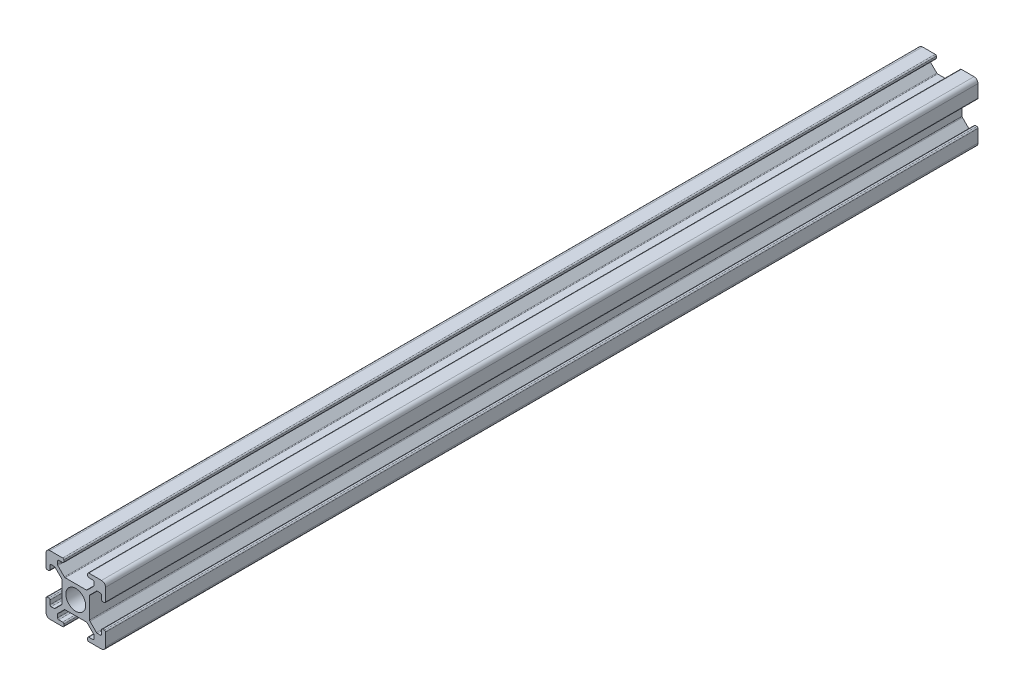
from build123d import *

# Parameters (mm, degrees)
SKETCH1_R           = 2.5
BOSS_EXTRUDE1_DEPTH = 220


with BuildPart() as part:
    # Sketch1 → Boss-Extrude1 (new body)
    with BuildSketch(Plane.XY):
        with BuildLine():
            Line((0.997149379, -0.010991612), (4.197149379, -0.010991612))
            ThreePointArc((4.197149379, -0.010991612), (4.409281413, 0.076876353), (4.497149379, 0.289008388))
            Line((4.497149379, 0.289008388), (4.497149379, 0.689008388))
            ThreePointArc((4.497149379, 0.689008388), (4.409281413, 0.901140422), (4.197149379, 0.989008388))
            Line((4.197149379, 0.989008388), (3.197149379, 0.989008388))
            ThreePointArc((3.197149379, 0.989008388), (2.985017344, 1.076876353), (2.897149379, 1.289008388))
            Line((2.897149379, 1.289008388), (2.897149379, 2.057637538))
            ThreePointArc((2.897149379, 2.057637538), (2.920422177, 2.174637797), (2.9866975, 2.273825827))
            Line((2.9866975, 2.273825827), (4.61806835, 3.905196677))
            ThreePointArc((4.61806835, 3.905196677), (4.71725638, 3.971472), (4.834256639, 3.994744798))
            Line((4.834256639, 3.994744798), (10.171514939, 3.994744798))
            ThreePointArc((10.171514939, 3.994744798), (10.288515198, 3.971472), (10.387703228, 3.905196677))
            Line((10.387703228, 3.905196677), (12.019074078, 2.273825827))
            ThreePointArc((12.019074078, 2.273825827), (12.085349401, 2.174637797), (12.1086222, 2.057637538))
            Line((12.1086222, 2.057637538), (12.1086222, 1.289008388))
            ThreePointArc((12.1086222, 1.289008388), (12.020754234, 1.076876353), (11.8086222, 0.989008388))
            Line((11.8086222, 0.989008388), (10.797149379, 0.989008388))
            ThreePointArc((10.797149379, 0.989008388), (10.585017344, 0.901140422), (10.497149379, 0.689008388))
            Line((10.497149379, 0.689008388), (10.497149379, 0.289008388))
            ThreePointArc((10.497149379, 0.289008388), (10.585017344, 0.076876353), (10.797149379, -0.010991612))
            Line((10.797149379, -0.010991612), (13.997149379, -0.010991612))
            ThreePointArc((13.997149379, -0.010991612), (14.70425616, 0.281901607), (14.997149379, 0.989008388))
            Line((14.997149379, 0.989008388), (14.997149379, 4.189008388))
            ThreePointArc((14.997149379, 4.189008388), (14.909281413, 4.401140422), (14.697149379, 4.489008388))
            Line((14.697149379, 4.489008388), (14.305261888, 4.489008388))
            ThreePointArc((14.305261888, 4.489008388), (14.093129854, 4.401140422), (14.005261888, 4.189008388))
            Line((14.005261888, 4.189008388), (14.005261888, 3.189008388))
            ThreePointArc((14.005261888, 3.189008388), (13.917393922, 2.976876353), (13.705261888, 2.889008388))
            Line((13.705261888, 2.889008388), (12.936632738, 2.889008388))
            ThreePointArc((12.936632738, 2.889008388), (12.819632479, 2.912281186), (12.720444449, 2.978556509))
            Line((12.720444449, 2.978556509), (11.089073599, 4.609927359))
            ThreePointArc((11.089073599, 4.609927359), (11.006246661, 4.70520219), (10.969948855, 4.826115648))
            Line((10.969948855, 4.826115648), (10.969948855, 10.163373948))
            ThreePointArc((10.969948855, 10.163373948), (11.00546556, 10.284783861), (11.087867966, 10.380761184))
            Line((11.087867966, 10.380761184), (12.719238816, 12.012132034))
            ThreePointArc((12.719238816, 12.012132034), (12.81656582, 12.07716386), (12.93137085, 12.1))
            Line((12.93137085, 12.1), (13.7, 12.1))
            ThreePointArc((13.7, 12.1), (13.912132034, 12.012132034), (14, 11.8))
            Line((14, 11.8), (14, 10.8))
            ThreePointArc((14, 10.8), (14.087867966, 10.587867966), (14.3, 10.5))
            Line((14.3, 10.5), (14.697149379, 10.5))
            ThreePointArc((14.697149379, 10.5), (14.909281413, 10.587867966), (14.997149379, 10.8))
            Line((14.997149379, 10.8), (14.997149379, 13.989008388))
            ThreePointArc((14.997149379, 13.989008388), (14.70425616, 14.696115169), (13.997149379, 14.989008388))
            Line((13.997149379, 14.989008388), (10.797149379, 14.989008388))
            ThreePointArc((10.797149379, 14.989008388), (10.585017344, 14.901140422), (10.497149379, 14.689008388))
            Line((10.497149379, 14.689008388), (10.497149379, 14.289008388))
            ThreePointArc((10.497149379, 14.289008388), (10.585017344, 14.076876353), (10.797149379, 13.989008388))
            Line((10.797149379, 13.989008388), (11.798829534, 13.989008388))
            ThreePointArc((11.798829534, 13.989008388), (12.010961569, 13.901140422), (12.098829534, 13.689008388))
            Line((12.098829534, 13.689008388), (12.098829534, 12.916322983))
            ThreePointArc((12.098829534, 12.916322983), (12.075993394, 12.801517953), (12.010961569, 12.704190949))
            Line((12.010961569, 12.704190949), (10.379590719, 11.072820099))
            ThreePointArc((10.379590719, 11.072820099), (10.282263714, 11.007788273), (10.167458684, 10.984952133))
            Line((10.167458684, 10.984952133), (4.830200384, 10.984952133))
            ThreePointArc((4.830200384, 10.984952133), (4.715395355, 11.007788273), (4.61806835, 11.072820099))
            Line((4.61806835, 11.072820099), (2.9866975, 12.704190949))
            ThreePointArc((2.9866975, 12.704190949), (2.920422177, 12.803378979), (2.897149379, 12.920379238))
            Line((2.897149379, 12.920379238), (2.897149379, 13.689008388))
            ThreePointArc((2.897149379, 13.689008388), (2.985017344, 13.901140422), (3.197149379, 13.989008388))
            Line((3.197149379, 13.989008388), (4.197149379, 13.989008388))
            ThreePointArc((4.197149379, 13.989008388), (4.409281413, 14.076876353), (4.497149379, 14.289008388))
            Line((4.497149379, 14.289008388), (4.497149379, 14.689008388))
            ThreePointArc((4.497149379, 14.689008388), (4.409281413, 14.901140422), (4.197149379, 14.989008388))
            Line((4.197149379, 14.989008388), (0.997149379, 14.989008388))
            ThreePointArc((0.997149379, 14.989008388), (0.290042597, 14.696115169), (-0.002850621, 13.989008388))
            Line((-0.002850621, 13.989008388), (-0.002850621, 10.789008388))
            ThreePointArc((-0.002850621, 10.789008388), (0.085017344, 10.576876353), (0.297149379, 10.489008388))
            Line((0.297149379, 10.489008388), (0.697149379, 10.489008388))
            ThreePointArc((0.697149379, 10.489008388), (0.909281413, 10.576876353), (0.997149379, 10.789008388))
            Line((0.997149379, 10.789008388), (0.997149379, 11.790199043))
            ThreePointArc((0.997149379, 11.790199043), (1.085017344, 12.002331078), (1.297149379, 12.090199043))
            Line((1.297149379, 12.090199043), (2.057928823, 12.090199043))
            ThreePointArc((2.057928823, 12.090199043), (2.174143192, 12.067250491), (2.272911478, 12.001849869))
            Line((2.272911478, 12.001849869), (3.912132034, 10.380761184))
            ThreePointArc((3.912132034, 10.380761184), (3.97928656, 10.281159192), (4.002885789, 10.163373948))
            Line((4.002885789, 10.163373948), (4.002885789, 4.826115648))
            ThreePointArc((4.002885789, 4.826115648), (3.979612991, 4.709115389), (3.913337668, 4.609927359))
            Line((3.913337668, 4.609927359), (2.281966818, 2.978556509))
            ThreePointArc((2.281966818, 2.978556509), (2.182778788, 2.912281186), (2.065778529, 2.889008388))
            Line((2.065778529, 2.889008388), (1.297149379, 2.889008388))
            ThreePointArc((1.297149379, 2.889008388), (1.085017344, 2.976876353), (0.997149379, 3.189008388))
            Line((0.997149379, 3.189008388), (0.997149379, 4.189008388))
            ThreePointArc((0.997149379, 4.189008388), (0.909281413, 4.401140422), (0.697149379, 4.489008388))
            Line((0.697149379, 4.489008388), (0.297149379, 4.489008388))
            ThreePointArc((0.297149379, 4.489008388), (0.085017344, 4.401140422), (-0.002850621, 4.189008388))
            Line((-0.002850621, 4.189008388), (-0.002850621, 0.989008388))
            ThreePointArc((-0.002850621, 0.989008388), (0.290042597, 0.281901607), (0.997149379, -0.010991612))
        make_face()
        with Locations((7.5, 7.5)):
            Circle(SKETCH1_R, mode=Mode.SUBTRACT)
    extrude(amount=BOSS_EXTRUDE1_DEPTH)


solid = part.part
